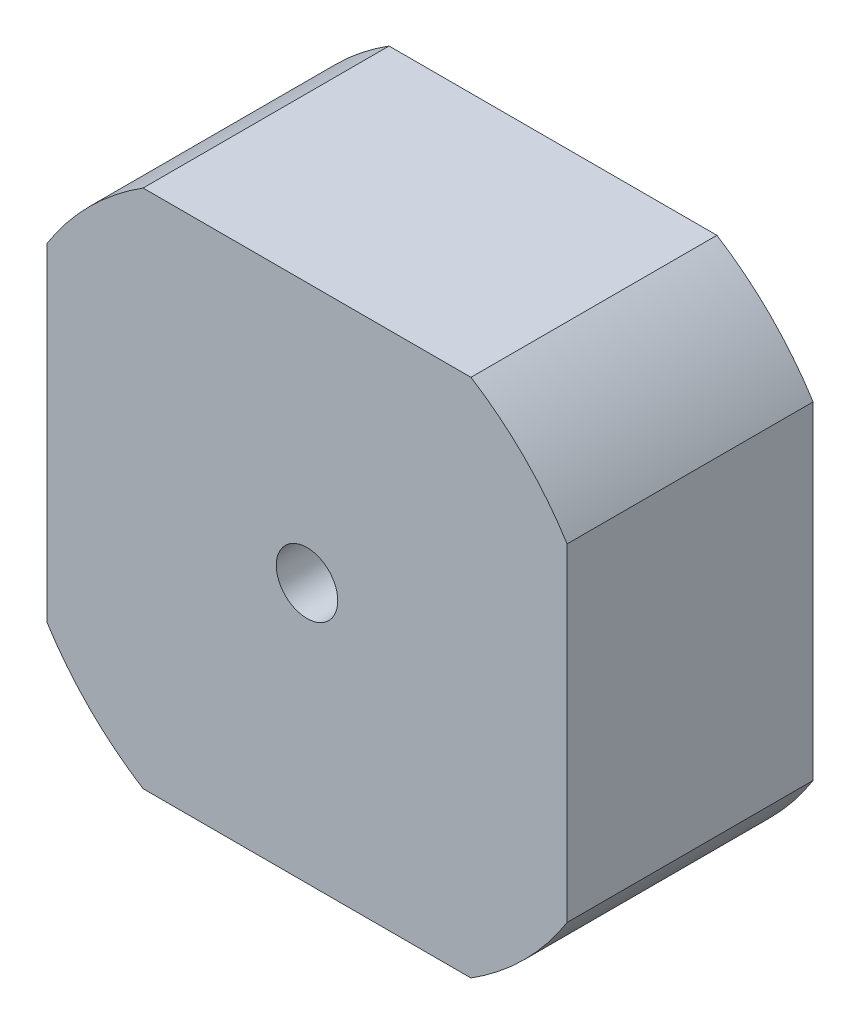
from build123d import *

# Parameters (mm, degrees)
SALIENTE_EXTRUIR1_DEPTH = 20
CROQUIS2_R              = 2.5
CORTAR_EXTRUIR1_DEPTH   = 21


with BuildPart() as part:
    # Croquis1 → Saliente-Extruir1 (new body)
    with BuildSketch(Plane.XY):
        with BuildLine():
            Line((-13.329572386, -21.15), (13.329572386, -21.15))
            ThreePointArc((13.329572386, -21.15), (17.67766953, -17.67766953), (21.15, -13.329572386))
            Line((21.15, -13.329572386), (21.15, 13.329572386))
            ThreePointArc((21.15, 13.329572386), (17.67766953, 17.67766953), (13.329572386, 21.15))
            Line((13.329572386, 21.15), (-13.329572386, 21.15))
            ThreePointArc((-13.329572386, 21.15), (-17.67766953, 17.67766953), (-21.15, 13.329572386))
            Line((-21.15, 13.329572386), (-21.15, -13.329572386))
            ThreePointArc((-21.15, -13.329572386), (-17.67766953, -17.67766953), (-13.329572386, -21.15))
        make_face()
    extrude(amount=SALIENTE_EXTRUIR1_DEPTH)

    # Croquis2 → Cortar-Extruir1 (cut, through all)
    with BuildSketch(Plane.XY.offset(20)):
        Circle(CROQUIS2_R)
    extrude(amount=-CORTAR_EXTRUIR1_DEPTH, mode=Mode.SUBTRACT)


solid = part.part
